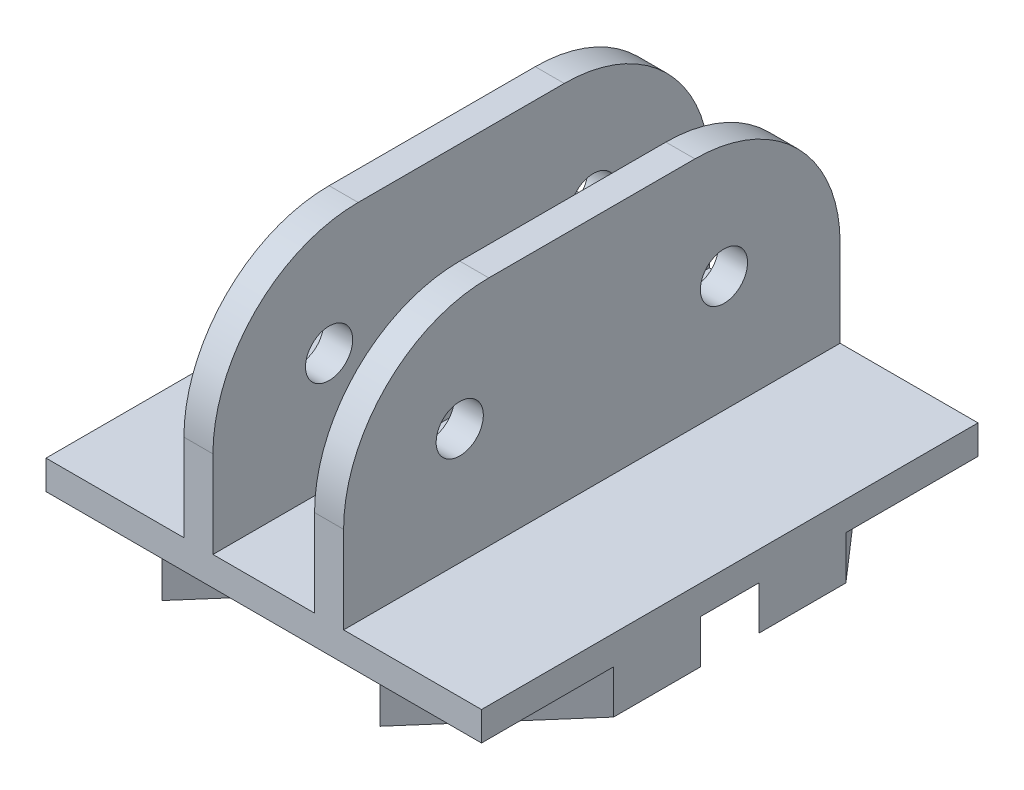
from build123d import *

# Parameters (mm, degrees)
BOSS_EXTRUDE1_DEPTH = 17.1
FILLET1_R           = 10
SKETCH5_R           = 1.625
CUT_EXTRUDE1_DEPTH  = 21.5
BOSS_EXTRUDE2_DEPTH = 3


with BuildPart() as part:
    # Sketch1 → Boss-Extrude1 (new body, symmetric)
    with BuildSketch(Plane.XY):
        Polygon((-5.5, 17), (-3.5, 17), (-3.5, 1), (3.5, 1), (3.5, 17), (5.5, 17), (5.5, 1), (15, 1), (15, -1), (-15, -1), (-15, 1), (-5.5, 1), align=None)
    extrude(amount=BOSS_EXTRUDE1_DEPTH, both=True)

    # Fillet1
    fillet1_edges = [part.edges().sort_by_distance(p)[0] for p in [
        (-4.5, 17, -17.1),
        (4.5, 17, -17.1),
        (4.5, 17, 17.1),
        (-4.5, 17, 17.1),
    ]]
    fillet(fillet1_edges, radius=FILLET1_R)

    # Sketch5 → Cut-Extrude1 (cut, through all)
    with BuildSketch(Plane.ZY.offset(5.5)):
        with Locations((-9.1, 9)):
            Circle(SKETCH5_R)
        with Locations((9.1, 9)):
            Circle(SKETCH5_R)
    extrude(amount=-CUT_EXTRUDE1_DEPTH, mode=Mode.SUBTRACT)

    # Sketch7 → Boss-Extrude2 (add)
    with BuildSketch(Plane.XZ.offset(1)):
        Polygon((-15, 8), (-7.5, 16.6), (0, 8), (7.5, 16.6), (15, 8), (15, 2), (7.5, 10.6), (0, 2), (-7.5, 10.6), (-15, 2), align=None)
        Polygon((-15, -2), (-7.5, -10.6), (0, -2), (7.5, -10.6), (15, -2), (15, -8), (7.5, -16.6), (0, -8), (-7.5, -16.6), (-15, -8), align=None)
    extrude(amount=BOSS_EXTRUDE2_DEPTH)


solid = part.part
